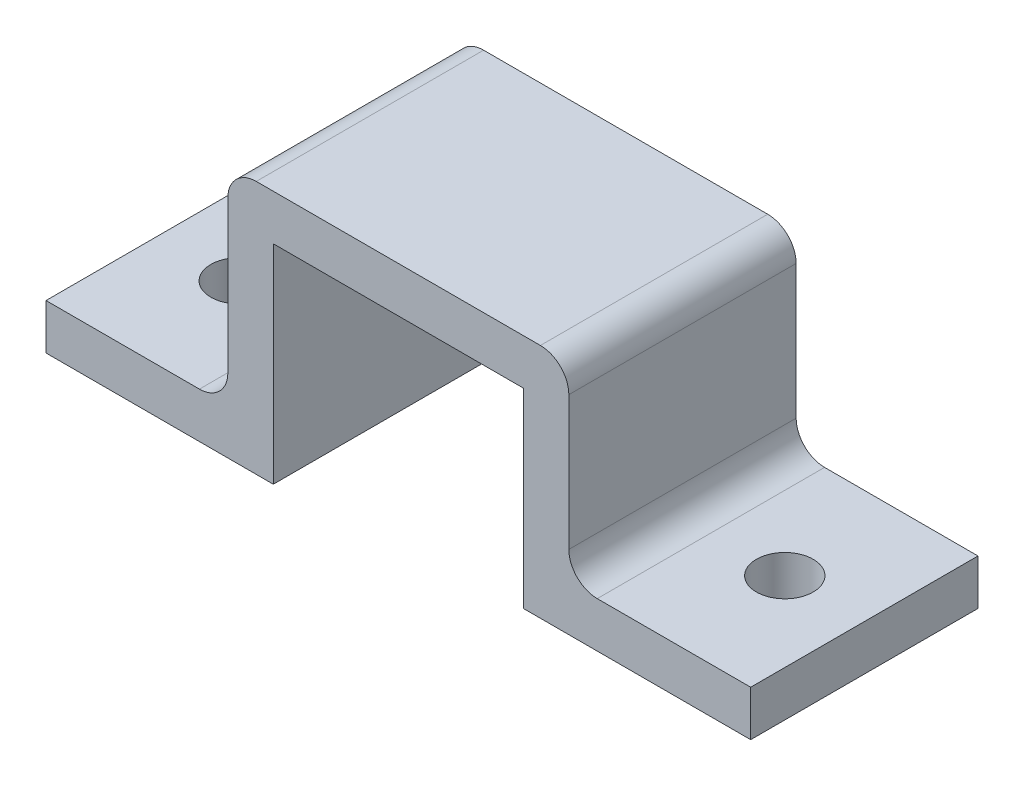
from build123d import *

# Parameters (mm, degrees)
BOSS_EXTRUDE1_DEPTH = 20
FILLET2_R           = 2.5
SKETCH2_R           = 2.5
CUT_EXTRUDE1_DEPTH  = 10
SKETCH3_R           = 2.5
CUT_EXTRUDE2_DEPTH  = 10


with BuildPart() as part:
    # Sketch1 → Boss-Extrude1 (new body)
    with BuildSketch(Plane.XY):
        Polygon((0, 0), (20, 0), (20, 18.325792173), (42, 18.325792173), (42, 1.536318489), (62, 1.536318489), (62, 5.536318489), (46, 5.536318489), (46, 22.325792173), (16, 22.325792173), (16, 4), (0, 4), align=None)
    extrude(amount=BOSS_EXTRUDE1_DEPTH)

    # Fillet2
    fillet2_edges = [part.edges().sort_by_distance(p)[0] for p in [
        (16, 4, 10),
        (16, 22.325792173, 10),
        (46, 22.325792173, 10),
        (46, 5.536318489, 10),
    ]]
    fillet(fillet2_edges, radius=FILLET2_R)

    # Sketch2 → Cut-Extrude1 (cut)
    with BuildSketch(Plane(origin=(0, 4, 0), x_dir=(1, 0, 0), z_dir=(0, 1, 0))):
        with Locations((7, -10)):
            Circle(SKETCH2_R)
    extrude(amount=-CUT_EXTRUDE1_DEPTH, mode=Mode.SUBTRACT)

    # Sketch3 → Cut-Extrude2 (cut)
    with BuildSketch(Plane(origin=(0, 5.536318489, 0), x_dir=(1, 0, 0), z_dir=(0, 1, 0))):
        with Locations((55, -10)):
            Circle(SKETCH3_R)
    extrude(amount=-CUT_EXTRUDE2_DEPTH, mode=Mode.SUBTRACT)


solid = part.part
